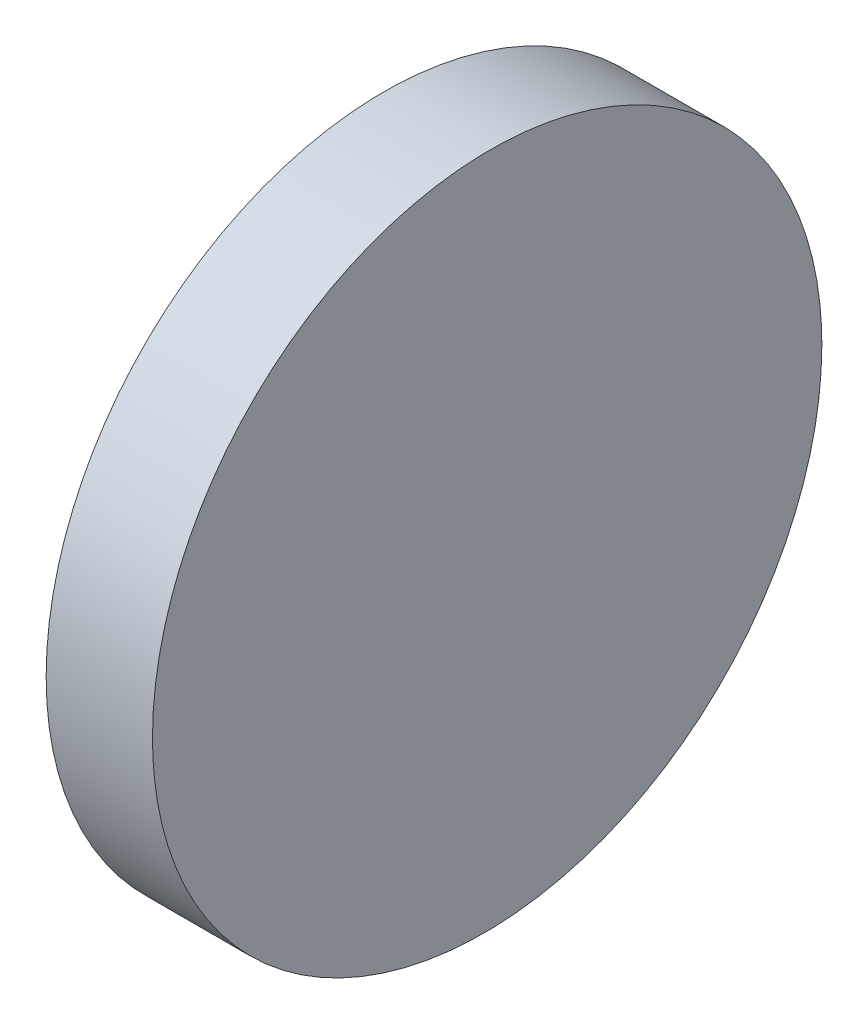
from build123d import *

# Parameters (mm, degrees)
EXTRUDE_1_DEPTH     = 50.8
CUT_EXTRUDE_2_DEPTH = 12.5


with BuildPart() as part:
    # 草图1 → 凸台-拉伸1 (new body)
    with BuildSketch(Plane(origin=(0, 0, 0), x_dir=(1, 0, 0), z_dir=(0, 1, 0))):
        Polygon((0, 25.4), (0, -25.4), (8, -25.4), (7.556675116, 25.4), align=None)
    extrude(amount=EXTRUDE_1_DEPTH)

    # 草图5 → 切除-拉伸2 (cut)
    with BuildSketch(Plane.ZY):
        with BuildLine():
            Line((-25.4, 50.8), (-25.4, 25.4))
            ThreePointArc((-25.4, 25.4), (-17.960512233, 43.360512251), (2.6e-08, 50.8))
            Line((2.6e-08, 50.8), (-25.4, 50.8))
        make_face()
        with BuildLine():
            Line((-25.4, 25.4), (-25.4, 0))
            Line((-25.4, 0), (-1.8e-08, 0))
            ThreePointArc((-1.8e-08, 0), (-17.960512249, 7.439487764), (-25.4, 25.4))
        make_face()
        with BuildLine():
            ThreePointArc((25.4, 25.4), (17.960512236, 7.439487751), (-1.8e-08, 0))
            Line((-1.8e-08, 0), (25.4, 0))
            Line((25.4, 0), (25.4, 25.4))
        make_face()
        with BuildLine():
            ThreePointArc((2.6e-08, 50.8), (17.960512251, 43.360512233), (25.4, 25.4))
            Line((25.4, 25.4), (25.4, 50.8))
            Line((25.4, 50.8), (2.6e-08, 50.8))
        make_face()
    extrude(amount=-CUT_EXTRUDE_2_DEPTH, mode=Mode.SUBTRACT)


solid = part.part
